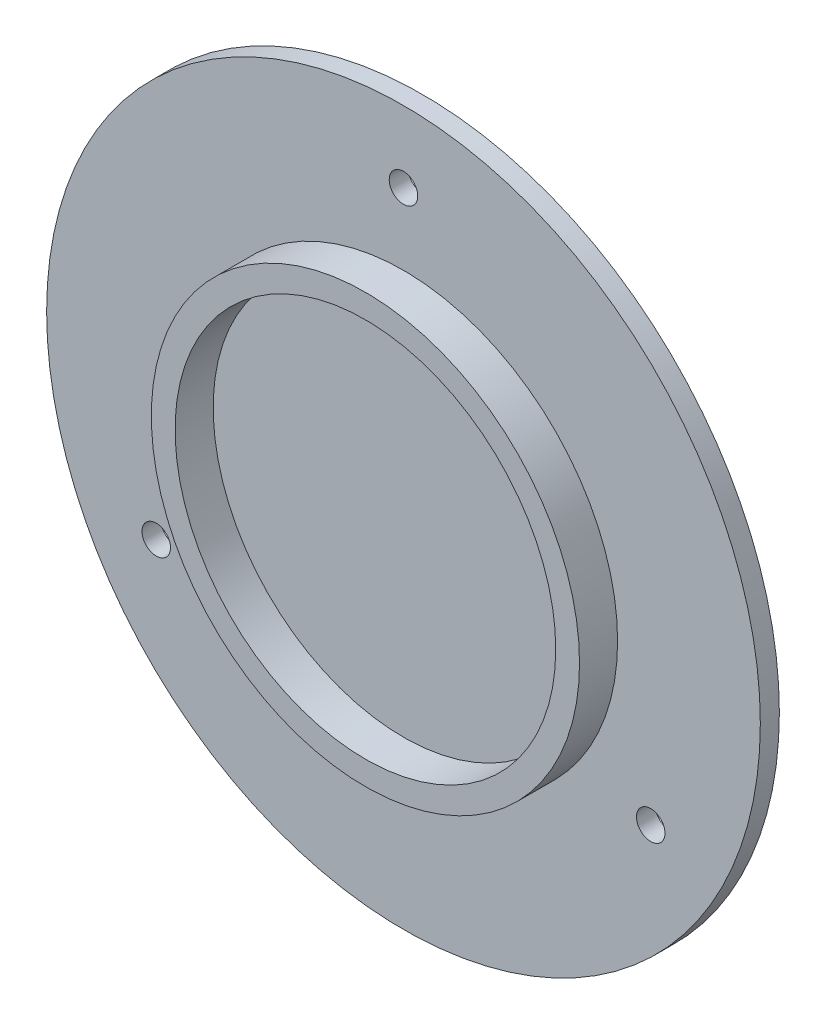
from build123d import *

# Parameters (mm, degrees)
SKETCH1_R           = 75
BOSS_EXTRUDE1_DEPTH = 4
SKETCH2_R           = 45
SKETCH2_R_2         = 40
BOSS_EXTRUDE2_DEPTH = 8
SKETCH4_R           = 3
CUT_EXTRUDE1_DEPTH  = 13


with BuildPart() as part:
    # Sketch1 → Boss-Extrude1 (new body)
    with BuildSketch(Plane.XY):
        Circle(SKETCH1_R)
    extrude(amount=BOSS_EXTRUDE1_DEPTH)

    # Sketch2 → Boss-Extrude2 (add)
    with BuildSketch(Plane.XY.offset(4)):
        Circle(SKETCH2_R)
        Circle(SKETCH2_R_2, mode=Mode.SUBTRACT)
    extrude(amount=BOSS_EXTRUDE2_DEPTH)

    # Sketch4 → Cut-Extrude1 (cut, through all)
    with BuildSketch(Plane(origin=(0, 0, 0), x_dir=(-1, 0, 0), z_dir=(0, 0, -1))):
        with Locations((0, 60)):
            Circle(SKETCH4_R)
        with Locations((51.961524227, -30)):
            Circle(SKETCH4_R)
        with Locations((-51.961524227, -30)):
            Circle(SKETCH4_R)
    extrude(amount=-CUT_EXTRUDE1_DEPTH, mode=Mode.SUBTRACT)


solid = part.part
